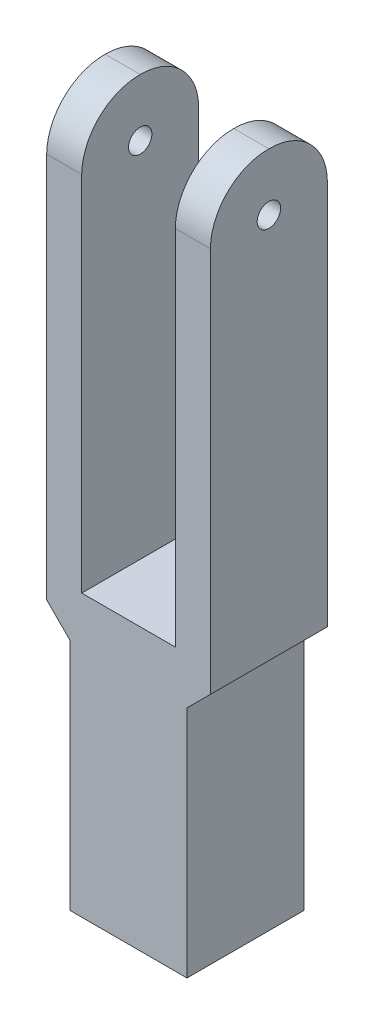
from build123d import *

# Parameters (mm, degrees)
SKETCH1_W           = 7
SKETCH1_H           = 5
BOSS_EXTRUDE1_DEPTH = 30
SKETCH3_W           = 1
SKETCH3_H           = 5
CUT_EXTRUDE1_DEPTH  = 10
SKETCH4_W           = 4
SKETCH4_H           = 5
CUT_EXTRUDE2_DEPTH  = 18
CUT_EXTRUDE3_REACH  = 7
CUT_EXTRUDE5_DEPTH  = 8
SKETCH8_R           = 0.5
CUT_EXTRUDE6_DEPTH  = 8
SKETCH9_R           = 1
CUT_EXTRUDE7_DEPTH  = 10


with BuildPart() as part:
    # Sketch1 → Boss-Extrude1 (new body)
    with BuildSketch(Plane(origin=(0, 0, 0), x_dir=(1, 0, 0), z_dir=(0, 1, 0))):
        Rectangle(SKETCH1_W, SKETCH1_H)
    extrude(amount=BOSS_EXTRUDE1_DEPTH)

    # Sketch3 → Cut-Extrude1 (cut)
    with BuildSketch(Plane.XZ):
        with Locations((-3, 0)):
            Rectangle(SKETCH3_W, SKETCH3_H)
        with Locations((3, 0)):
            Rectangle(SKETCH3_W, SKETCH3_H)
    extrude(amount=-CUT_EXTRUDE1_DEPTH, mode=Mode.SUBTRACT)

    # Sketch4 → Cut-Extrude2 (cut)
    with BuildSketch(Plane(origin=(0, 30, 0), x_dir=(1, 0, 0), z_dir=(0, 1, 0))):
        Rectangle(SKETCH4_W, SKETCH4_H)
    extrude(amount=-CUT_EXTRUDE2_DEPTH, mode=Mode.SUBTRACT)

    # Sketch5 → Cut-Extrude3 (cut, up to next)
    with BuildSketch(Plane.XY.offset(2.5), mode=Mode.PRIVATE) as cut_extrude3_sk1:
        Polygon((-3.5, 10), (-2.5, 10), (-3.5, 11), align=None)
    cut_extrude3_tool1 = extrude(cut_extrude3_sk1.sketch, amount=-CUT_EXTRUDE3_REACH, mode=Mode.PRIVATE) & part.part
    add(cut_extrude3_tool1.solids().sort_by_distance((-3.166667, 10.333333, 2.5))[0], mode=Mode.SUBTRACT)
    # Sketch5 → Cut-Extrude3 (cut, up to next)
    with BuildSketch(Plane.XY.offset(2.5), mode=Mode.PRIVATE) as cut_extrude3_sk2:
        Polygon((3.5, 11), (3.5, 10), (2.5, 10), align=None)
    cut_extrude3_tool2 = extrude(cut_extrude3_sk2.sketch, amount=-CUT_EXTRUDE3_REACH, mode=Mode.PRIVATE) & part.part
    add(cut_extrude3_tool2.solids().sort_by_distance((3.166667, 10.333333, 2.5))[0], mode=Mode.SUBTRACT)

    # Sketch7 → Cut-Extrude5 (cut, through all)
    with BuildSketch(Plane(origin=(3.5, 0, 0), x_dir=(0, 0, -1), z_dir=(1, 0, 0))):
        with BuildLine():
            Line((-2.5, 27.5), (-2.5, 30))
            Line((-2.5, 30), (2.5, 30))
            Line((2.5, 30), (2.5, 27.5))
            ThreePointArc((2.5, 27.5), (1.756951521, 29.241656191), (0, 29.947778476))
            ThreePointArc((0, 29.947778476), (-1.756951521, 29.241656191), (-2.5, 27.5))
        make_face()
    extrude(amount=-CUT_EXTRUDE5_DEPTH, mode=Mode.SUBTRACT)

    # Sketch8 → Cut-Extrude6 (cut, through all)
    with BuildSketch(Plane(origin=(3.5, 0, 0), x_dir=(0, 0, -1), z_dir=(1, 0, 0))):
        with Locations((0, 27.5)):
            Circle(SKETCH8_R)
    extrude(amount=-CUT_EXTRUDE6_DEPTH, mode=Mode.SUBTRACT)

    # Sketch9 → Cut-Extrude7 (cut)
    with BuildSketch(Plane.XZ):
        Circle(SKETCH9_R)
    extrude(amount=-CUT_EXTRUDE7_DEPTH, mode=Mode.SUBTRACT)


solid = part.part
